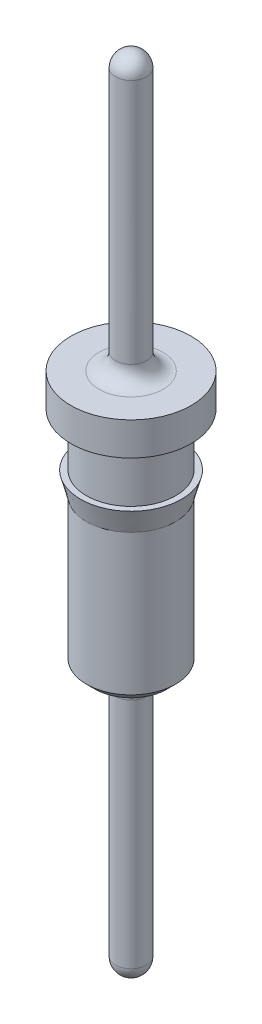
from build123d import *

# Parameters (mm, degrees)
DOME1_FACE_RADIUS = 0.235
DOME1_HEIGHT      = 0.235
DOME2_FACE_RADIUS = 0.235
DOME2_HEIGHT      = 0.235
FILLET1_R         = 0.25


with BuildPart() as part:
    # Sketch1 → Revolve1 (revolve)
    with BuildSketch(Plane.XY):
        Polygon((0, 0), (0, 11.64), (0.235, 11.64), (0.235, 7.67), (0.91, 7.67), (0.91, 7.17), (0.675, 7.17), (0.675, 6.37), (0.765, 6.37), (0.675, 6.03), (0.675, 3.9), (0.545, 3.77), (0.235, 3.77), (0.235, 0), align=None)
    revolve(axis=Axis((0, 0, 0), (0, 1, 0)))

    # Dome1: a dome of height H over a round flat face of radius A is a cap of a sphere of radius (A * A + H * H) / (2 * H)
    dome1_r = (DOME1_FACE_RADIUS * DOME1_FACE_RADIUS + DOME1_HEIGHT * DOME1_HEIGHT) / (2 * DOME1_HEIGHT)
    dome1_base = Plane((0, 11.64, 0), z_dir=(0, 1, 0))
    with Locations(dome1_base.offset(DOME1_HEIGHT - dome1_r)):
        dome1_ball = Sphere(dome1_r, mode=Mode.PRIVATE)
    add(split(dome1_ball, bisect_by=dome1_base, keep=Keep.TOP, mode=Mode.PRIVATE))

    # Dome2: a dome of height H over a round flat face of radius A is a cap of a sphere of radius (A * A + H * H) / (2 * H)
    dome2_r = (DOME2_FACE_RADIUS * DOME2_FACE_RADIUS + DOME2_HEIGHT * DOME2_HEIGHT) / (2 * DOME2_HEIGHT)
    dome2_base = Plane((0, 0, 0), z_dir=(0, -1, 0))
    with Locations(dome2_base.offset(DOME2_HEIGHT - dome2_r)):
        dome2_ball = Sphere(dome2_r, mode=Mode.PRIVATE)
    add(split(dome2_ball, bisect_by=dome2_base, keep=Keep.TOP, mode=Mode.PRIVATE))

    # Fillet1
    fillet1_edges = [part.edges().sort_by_distance(p)[0] for p in [
        (-0.235, 7.67, 0),
        (-0.235, 3.77, 0),
    ]]
    fillet(fillet1_edges, radius=FILLET1_R)


solid = part.part
